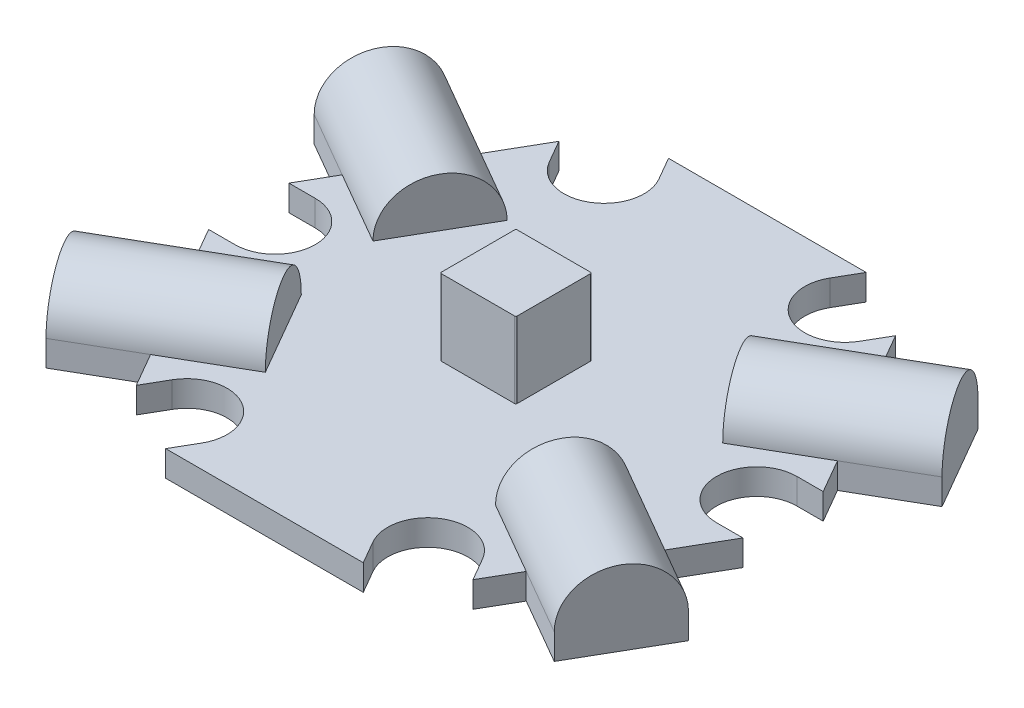
from build123d import *

# Parameters (mm, degrees)
BOSS_EXTRUDE1_DEPTH  = 1.016
CUT_EXTRUDE1_DEPTH   = 1.016
CIRPATTERN1_COUNT    = 6
SKETCH3_W            = 3
SKETCH3_H            = 3
BOSS_EXTRUDE2_DEPTH  = 3
FILLET1_R            = 0.0508
FILLET2_R            = 0.0508
FILLET3_R            = 0.0508
FILLET4_R            = 0.0508
BOSS_EXTRUDE3_DEPTH  = 6.35
CIRPATTERN2_COUNT    = 2
CIRPATTERN2_ANGLE    = 60
BOSS_EXTRUDE4_DEPTH  = 1.016
BOSS_EXTRUDE5_DEPTH  = 1.016
MIRROR1_COPY_1_DEPTH = 6.35


with BuildPart() as part:
    # Sketch1 → Boss-Extrude1 (new body)
    with BuildSketch(Plane(origin=(0, 0, 0), x_dir=(1, 0, 0), z_dir=(0, 1, 0))):
        Polygon((5.741228812, 9.9441), (-5.741228812, 9.9441), (-11.482457624, 0), (-5.741228812, -9.9441), (5.741228812, -9.9441), (11.482457624, 0), align=None)
    extrude(amount=BOSS_EXTRUDE1_DEPTH)

    # Sketch2 → Cut-Extrude1 (cut)
    with BuildSketch(Plane(origin=(0, 1.016, 0), x_dir=(1, 0, 0), z_dir=(0, 1, 0))):
        with BuildLine():
            Line((9.525, 1.5875), (13.137780832, 1.5875))
            Line((13.137780832, 1.5875), (13.137780832, -1.5875))
            Line((13.137780832, -1.5875), (9.525, -1.5875))
            ThreePointArc((9.525, -1.5875), (7.9375, 0), (9.525, 1.5875))
        make_face()
    cut_extrude1 = extrude(amount=-CUT_EXTRUDE1_DEPTH, mode=Mode.SUBTRACT)

    # CirPattern1: Cut-Extrude1 ×6 about axis
    cirpattern1_axis = Axis((0, 0, 0), (0, 1, 0))
    for i in range(1, CIRPATTERN1_COUNT):
        add(cut_extrude1.rotate(cirpattern1_axis, i * 360 / CIRPATTERN1_COUNT), mode=Mode.SUBTRACT)

    # Sketch3 → Boss-Extrude2 (add)
    with BuildSketch(Plane(origin=(0, 1.016, 0), x_dir=(1, 0, 0), z_dir=(0, 1, 0))):
        Rectangle(SKETCH3_W, SKETCH3_H)
    extrude(amount=BOSS_EXTRUDE2_DEPTH)

    # Fillet1
    fillet1_edges = [part.edges().sort_by_distance(p)[0] for p in [
        (1.5, 2.516, 1.5),
    ]]
    fillet(fillet1_edges, radius=FILLET1_R)

    # Fillet2
    fillet2_edges = [part.edges().sort_by_distance(p)[0] for p in [
        (-1.5, 2.516, -1.5),
    ]]
    fillet(fillet2_edges, radius=FILLET2_R)

    # Fillet3
    fillet3_edges = [part.edges().sort_by_distance(p)[0] for p in [
        (1.5, 2.516, -1.5),
    ]]
    fillet(fillet3_edges, radius=FILLET3_R)

    # Fillet4
    fillet4_edges = [part.edges().sort_by_distance(p)[0] for p in [
        (-1.5, 2.516, 1.5),
    ]]
    fillet(fillet4_edges, radius=FILLET4_R)

    # Sketch5 → Boss-Extrude3 (add)
    with BuildSketch(Plane(origin=(-5.734684765, 0, 3.310921793), x_dir=(0.5, 0, 0.866025404), z_dir=(-0.866025404, 0, 0.5))):
        with BuildLine():
            ThreePointArc((-1.520793442, 1.016), (0.422306558, 2.9591), (2.365406558, 1.016))
            Line((2.365406558, 1.016), (-1.520793442, 1.016))
        make_face()
    boss_extrude3 = extrude(amount=BOSS_EXTRUDE3_DEPTH)

    # CirPattern2: Boss-Extrude3 ×2 about axis
    cirpattern2_axis = Axis((0, 4.2168, 0), (0, -1, 0))
    for i in range(1, CIRPATTERN2_COUNT):
        add(boss_extrude3.rotate(cirpattern2_axis, i * CIRPATTERN2_ANGLE / (CIRPATTERN2_COUNT - 1)))

    # Sketch7 → Boss-Extrude4 (add)
    with BuildSketch(Plane.XZ.offset(-1.016)):
        Polygon((-11.9943428, 5.168876038), (-9.372239939, 3.655004245), (-7.429139939, 7.020552169), (-10.0512428, 8.534423962), align=None)
    boss_extrude4 = extrude(amount=BOSS_EXTRUDE4_DEPTH)

    # Sketch8 → Boss-Extrude5 (add)
    with BuildSketch(Plane.XZ.offset(-1.016)):
        Polygon((-10.473549358, -7.802967548), (-7.851446497, -6.289095755), (-9.794546497, -2.923547831), (-12.416649358, -4.437419623), align=None)
    boss_extrude5 = extrude(amount=BOSS_EXTRUDE5_DEPTH)

    # Mirror1: Boss-Extrude5, Boss-Extrude4, Boss-Extrude3 across plane
    add(boss_extrude5.mirror(Plane(origin=(0, 0, 0), x_dir=(0, 0, 1), z_dir=(1, 0, 0))))
    add(boss_extrude4.mirror(Plane(origin=(0, 0, 0), x_dir=(0, 0, 1), z_dir=(1, 0, 0))))
    add(boss_extrude3.mirror(Plane(origin=(0, 0, 0), x_dir=(0, 0, 1), z_dir=(1, 0, 0))))

    # Mirror1 copy 1 sketch → Mirror1 copy 1 (add)
    with BuildSketch(Plane(origin=(5.734684765, 0, -3.310921793), x_dir=(0.5, 0, 0.866025404), z_dir=(0.866025404, 0, -0.5))):
        with BuildLine():
            ThreePointArc((-1.520793442, -1.016), (0.422306558, -2.9591), (2.365406558, -1.016))
            Line((2.365406558, -1.016), (-1.520793442, -1.016))
        make_face()
    extrude(amount=MIRROR1_COPY_1_DEPTH)


solid = part.part
